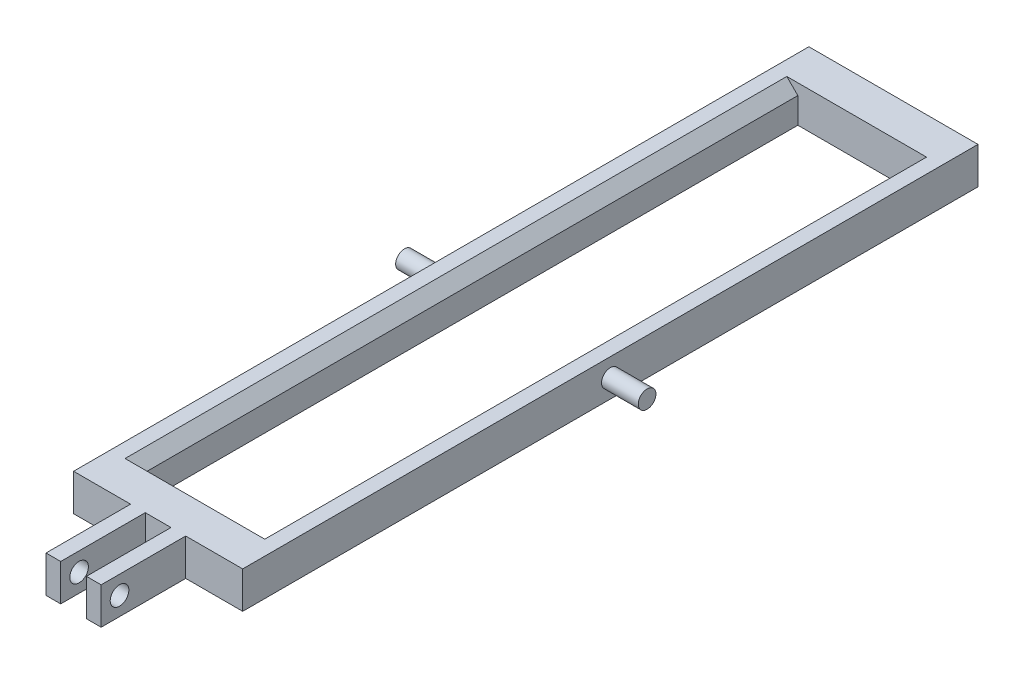
from build123d import *

# Parameters (mm, degrees)
BOSS_EXTRUDE1_DEPTH   = 200
BOSS_EXTRUDE1_2_DEPTH = 200
SKETCH2_R             = 2.4
BOSS_EXTRUDE2_DEPTH   = 10
SKETCH3_R             = 2.4
BOSS_EXTRUDE3_DEPTH   = 10
SKETCH4_W             = 46
SKETCH4_H             = 10
BOSS_EXTRUDE4_DEPTH   = 10
BOSS_EXTRUDE5_START   = 3.5
SKETCH5_W             = 33
SKETCH5_H             = 10
SKETCH5_R             = 2.535
BOSS_EXTRUDE5_DEPTH   = 4


with BuildPart() as part:
    # Sketch1 → Boss-Extrude1 (new body)
    with BuildSketch(Plane.XY):
        Polygon((4, 10), (7, 7), (7, 0), (0, 0), (0, 10), align=None)
    extrude(amount=BOSS_EXTRUDE1_DEPTH)

    # Sketch3 → Boss-Extrude3 (add)
    with BuildSketch(Plane.ZY):
        with Locations((100, 5)):
            Circle(SKETCH3_R)
    extrude(amount=BOSS_EXTRUDE3_DEPTH)



with BuildPart() as body_2:
    # Sketch1 → Boss-Extrude1 2 (new body)
    with BuildSketch(Plane.XY):
        Polygon((39, 0), (39, 7), (42, 10), (46, 10), (46, 0), align=None)
    extrude(amount=BOSS_EXTRUDE1_2_DEPTH)

    # Sketch2 → Boss-Extrude2 (add)
    with BuildSketch(Plane(origin=(46, 0, 0), x_dir=(0, 0, -1), z_dir=(1, 0, 0))):
        with Locations((-100, 5)):
            Circle(SKETCH2_R)
    extrude(amount=BOSS_EXTRUDE2_DEPTH)


with BuildPart() as part_1:
    add(part.part)

    add(body_2.part)  # Boss-Extrude4 merges body 2
    # Sketch4 → Boss-Extrude4 (add)
    with BuildSketch(Plane.XZ):
        with Locations((23, 195)):
            Rectangle(SKETCH4_W, SKETCH4_H)
    boss_extrude4 = extrude(amount=-BOSS_EXTRUDE4_DEPTH)

    # Mirror3: Boss-Extrude4 across plane
    add(boss_extrude4.mirror(Plane(origin=(0, 0, 100), x_dir=(1, 0, 0), z_dir=(0, 0, -1))))

    # Sketch5 → Boss-Extrude5 (add)
    with BuildSketch(Plane(origin=(23, 0, 0), x_dir=(0, 0, -1), z_dir=(1, 0, 0)).offset(BOSS_EXTRUDE5_START)):
        with Locations((-206.5, 5)):
            Rectangle(SKETCH5_W, SKETCH5_H)
        with Locations((-218, 5)):
            Circle(SKETCH5_R, mode=Mode.SUBTRACT)
    boss_extrude5 = extrude(amount=BOSS_EXTRUDE5_DEPTH)

    # Mirror4: Boss-Extrude5 across plane
    add(boss_extrude5.mirror(Plane(origin=(23, 0, 0), x_dir=(0, 0, 1), z_dir=(1, 0, 0))))


solid = part_1.part
